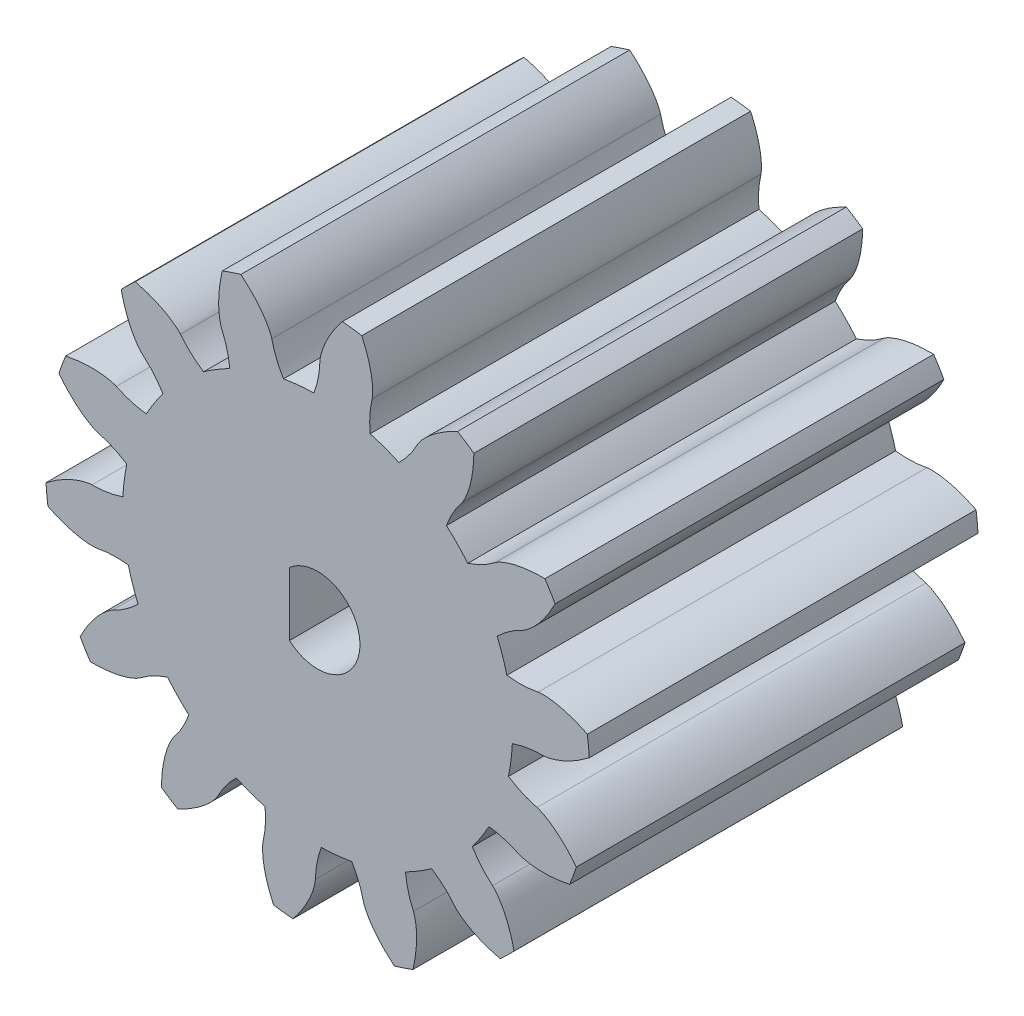
from build123d import *

# Parameters (mm, degrees)
EXTRUDE_1_DEPTH     = 17
CUT_EXTRUDE_1_DEPTH = 14
SKETCH_5_R          = 2.5
CUT_EXTRUDE_2_DEPTH = 10


with BuildPart() as part:
    # 草图3 → 凸台-拉伸1 (new body)
    with BuildSketch(Plane.XY):
        with BuildLine():
            ThreePointArc((-3.841308616, 7.61051727), (-4.427490026, 7.285118878), (-4.986287774, 6.914662626))
            add(Edge.make_bspline(
                [(-4.986287774, 6.914662626), (-5.374015095, 7.164837573), (-5.712687805, 7.469086191), (-5.997843823, 7.832327104)],
                knots=[0, 0, 0, 0, 1, 1, 1, 1], degree=3))
            add(Edge.make_bspline(
                [(-5.997843823, 7.832327104), (-6.02722682, 7.869756111), (-6.060990815, 7.9020808), (-6.129381664, 7.965724859), (-6.164838005, 7.996077789), (-6.273808403, 8.084105708), (-6.350214832, 8.138816882), (-6.585221896, 8.292908353), (-6.749357091, 8.382209705), (-7.257478206, 8.621843869), (-7.612180761, 8.741400879), (-7.975878143, 8.831498618)],
                knots=[0, 0, 0, 0, 0.0625, 0.0625, 0.125, 0.125, 0.25, 0.25, 0.5, 0.5, 1, 1, 1, 1], degree=3))
            ThreePointArc((-7.975878143, 8.831498618), (-8.288227949, 8.539044295), (-8.589861649, 8.235549578))
            add(Edge.make_bspline(
                [(-8.589861649, 8.235549578), (-8.510609476, 7.869170738), (-8.400968963, 7.509224231), (-8.176815523, 6.995154162), (-8.091644293, 6.827136538), (-7.945256312, 6.588944119), (-7.89337007, 6.511759663), (-7.808989012, 6.400674841), (-7.779790112, 6.364414172), (-7.718240864, 6.29414968), (-7.686959773, 6.259380129), (-7.650087487, 6.228614597)],
                knots=[0, 0, 0, 0, 0.5, 0.5, 0.75, 0.75, 0.875, 0.875, 0.9375, 0.9375, 1, 1, 1, 1], degree=3))
            add(Edge.make_bspline(
                [(-7.650087487, 6.228614597), (-7.295506751, 5.932759196), (-7.001487118, 5.585169089), (-6.762979163, 5.190157779)],
                knots=[0, 0, 0, 0, 1, 1, 1, 1], degree=3))
            ThreePointArc((-6.762979163, 5.190157779), (-7.149925292, 4.642649378), (-7.492649722, 4.066426573))
            add(Edge.make_bspline(
                [(-7.492649722, 4.066426573), (-7.950526809, 4.123597832), (-8.387668907, 4.250771784), (-8.802189929, 4.454315979)],
                knots=[0, 0, 0, 0, 1, 1, 1, 1], degree=3))
            add(Edge.make_bspline(
                [(-8.802189929, 4.454315979), (-8.844902932, 4.475289544), (-8.889348398, 4.489763435), (-8.978580545, 4.517431073), (-9.023695248, 4.529394188), (-9.160068066, 4.56142412), (-9.252646169, 4.577565676), (-9.531238001, 4.614431551), (-9.717865106, 4.623673697), (-10.279639779, 4.61911113), (-10.651089581, 4.572928602), (-11.017861544, 4.49630148)],
                knots=[0, 0, 0, 0, 0.0625, 0.0625, 0.125, 0.125, 0.25, 0.25, 0.5, 0.5, 1, 1, 1, 1], degree=3))
            ThreePointArc((-11.017861544, 4.49630148), (-11.172387819, 4.097285738), (-11.31246897, 3.692972489))
            add(Edge.make_bspline(
                [(-11.31246897, 3.692972489), (-11.082099408, 3.39726279), (-10.827141783, 3.120533428), (-10.402139868, 2.754628833), (-10.252503126, 2.640204596), (-10.017264296, 2.489116006), (-9.937027327, 2.442087811), (-9.812804723, 2.378615414), (-9.770764509, 2.358614608), (-9.684823931, 2.322013706), (-9.641554699, 2.30425978), (-9.594985253, 2.292539279)],
                knots=[0, 0, 0, 0, 0.5, 0.5, 0.75, 0.75, 0.875, 0.875, 0.9375, 0.9375, 1, 1, 1, 1], degree=3))
            add(Edge.make_bspline(
                [(-9.594985253, 2.292539279), (-9.147152201, 2.179829589), (-8.73143597, 1.994232061), (-8.345158744, 1.741823892)],
                knots=[0, 0, 0, 0, 1, 1, 1, 1], degree=3))
            ThreePointArc((-8.345158744, 1.741823892), (-8.456230167, 1.080646235), (-8.515000504, 0.412784869))
            add(Edge.make_bspline(
                [(-8.515000504, 0.412784869), (-8.952339185, 0.265628971), (-9.401369315, 0.190539894), (-9.863154368, 0.194072946)],
                knots=[0, 0, 0, 0, 1, 1, 1, 1], degree=3))
            add(Edge.make_bspline(
                [(-9.863154368, 0.194072946), (-9.910737543, 0.194436998), (-9.957061509, 0.188193358), (-10.049461434, 0.174404661), (-10.095298978, 0.165608519), (-10.232063908, 0.135296542), (-10.322477455, 0.109671449), (-10.589475527, 0.022009988), (-10.761630756, -0.050637592), (-11.265792622, -0.298493219), (-11.580419482, -0.501268267), (-11.87762234, -0.729443309)],
                knots=[0, 0, 0, 0, 0.0625, 0.0625, 0.125, 0.125, 0.25, 0.25, 0.5, 0.5, 1, 1, 1, 1], degree=3))
            ThreePointArc((-11.87762234, -0.729443309), (-11.843719261, -1.155990509), (-11.794503073, -1.581043093))
            add(Edge.make_bspline(
                [(-11.794503073, -1.581043093), (-11.45864364, -1.747514719), (-11.108866387, -1.88621729), (-10.567192839, -2.03148452), (-10.382727977, -2.069652246), (-10.105230232, -2.103712058), (-10.012534452, -2.111269482), (-9.873074112, -2.114557967), (-9.826519163, -2.114337506), (-9.733208842, -2.11002556), (-9.686521471, -2.107247479), (-9.639478515, -2.09760156)],
                knots=[0, 0, 0, 0, 0.5, 0.5, 0.75, 0.75, 0.875, 0.875, 0.9375, 0.9375, 1, 1, 1, 1], degree=3))
            add(Edge.make_bspline(
                [(-9.639478515, -2.09760156), (-9.187091976, -2.004842003), (-8.732016845, -1.991687084), (-8.274477289, -2.051499579)],
                knots=[0, 0, 0, 0, 1, 1, 1, 1], degree=3))
            ThreePointArc((-8.274477289, -2.051499579), (-8.087674949, -2.695392149), (-7.850851007, -3.322613941))
            add(Edge.make_bspline(
                [(-7.850851007, -3.322613941), (-8.181030991, -3.644950967), (-8.553013231, -3.907430759), (-8.97060012, -4.104608614)],
                knots=[0, 0, 0, 0, 1, 1, 1, 1], degree=3))
            add(Edge.make_bspline(
                [(-8.97060012, -4.104608614), (-9.013629036, -4.124926181), (-9.052656474, -4.150650721), (-9.129923238, -4.203164733), (-9.167404935, -4.230977948), (-9.277474005, -4.317628175), (-9.347815485, -4.379944554), (-9.550337553, -4.574770923), (-9.673923451, -4.714919485), (-10.020617071, -5.156977325), (-10.216105281, -5.476182809), (-10.384874363, -5.810712905)],
                knots=[0, 0, 0, 0, 0.0625, 0.0625, 0.125, 0.125, 0.25, 0.25, 0.5, 0.5, 1, 1, 1, 1], degree=3))
            ThreePointArc((-10.384874363, -5.810712905), (-10.16925685, -6.180308658), (-9.940491192, -6.5419137))
            add(Edge.make_bspline(
                [(-9.940491192, -6.5419137), (-9.565662967, -6.546175506), (-9.190343761, -6.519379542), (-8.63928367, -6.415237449), (-8.456526216, -6.369589078), (-8.191731388, -6.279874149), (-8.104936333, -6.246463961), (-7.977860088, -6.18891721), (-7.936011183, -6.168519146), (-7.853812372, -6.124148386), (-7.812953868, -6.10138853), (-7.774754837, -6.072286684)],
                knots=[0, 0, 0, 0, 0.5, 0.5, 0.75, 0.75, 0.875, 0.875, 0.9375, 0.9375, 1, 1, 1, 1], degree=3))
            add(Edge.make_bspline(
                [(-7.774754837, -6.072286684), (-7.407415513, -5.792430048), (-7.003114692, -5.583128176), (-6.564934127, -5.438498399)],
                knots=[0, 0, 0, 0, 1, 1, 1, 1], degree=3))
            ThreePointArc((-6.564934127, -5.438498399), (-6.117256519, -5.937575061), (-5.631744183, -6.399928311))
            add(Edge.make_bspline(
                [(-5.631744183, -6.399928311), (-5.789369276, -6.833603662), (-6.01062798, -7.231486828), (-6.301308502, -7.590322098)],
                knots=[0, 0, 0, 0, 1, 1, 1, 1], degree=3))
            add(Edge.make_bspline(
                [(-6.301308502, -7.590322098), (-6.331260753, -7.62729714), (-6.3552618, -7.667407521), (-6.402091773, -7.748245804), (-6.423793913, -7.789567343), (-6.485366595, -7.91539368), (-6.521704015, -8.002058822), (-6.6196381, -8.265462347), (-6.670176964, -8.44535375), (-6.790735414, -8.994058825), (-6.828366136, -9.366472184), (-6.835274656, -9.741099547)],
                knots=[0, 0, 0, 0, 0.0625, 0.0625, 0.125, 0.125, 0.25, 0.25, 0.5, 0.5, 1, 1, 1, 1], degree=3))
            ThreePointArc((-6.835274656, -9.741099547), (-6.480648402, -9.980540881), (-6.117643119, -10.207078067))
            add(Edge.make_bspline(
                [(-6.117643119, -10.207078067), (-5.778085429, -10.04828595), (-5.451560842, -9.86129872), (-5.000258416, -9.528373923), (-4.855405726, -9.407950675), (-4.655759678, -9.212230147), (-4.592056173, -9.144469645), (-4.502533032, -9.037485498), (-4.47367886, -9.000949917), (-4.418872041, -8.925308516), (-4.391934933, -8.887074754), (-4.370145612, -8.844280959)],
                knots=[0, 0, 0, 0, 0.5, 0.5, 0.75, 0.75, 0.875, 0.875, 0.9375, 0.9375, 1, 1, 1, 1], degree=3))
            add(Edge.make_bspline(
                [(-4.370145612, -8.844280959), (-4.160609561, -8.432756282), (-3.887159787, -8.06876226), (-3.555125248, -7.748335911)],
                knots=[0, 0, 0, 0, 1, 1, 1, 1], degree=3))
            ThreePointArc((-3.555125248, -7.748335911), (-2.935240412, -8.003748412), (-2.297201355, -8.209658389))
            add(Edge.make_bspline(
                [(-2.297201355, -8.209658389), (-2.251051974, -8.668777344), (-2.277764142, -9.123258243), (-2.383965454, -9.572679202)],
                knots=[0, 0, 0, 0, 1, 1, 1, 1], degree=3))
            add(Edge.make_bspline(
                [(-2.383965454, -9.572679202), (-2.394908631, -9.618988358), (-2.399129584, -9.665540227), (-2.406247516, -9.758691767), (-2.407871725, -9.805337393), (-2.408752793, -9.94541839), (-2.403889081, -10.039267201), (-2.377838136, -10.319077583), (-2.345320125, -10.503082128), (-2.215865325, -11.04975667), (-2.088185334, -11.401616871), (-1.931864974, -11.742141956)],
                knots=[0, 0, 0, 0, 0.0625, 0.0625, 0.125, 0.125, 0.25, 0.25, 0.5, 0.5, 1, 1, 1, 1], degree=3))
            ThreePointArc((-1.931864974, -11.742141956), (-1.508468058, -11.80400458), (-1.083120798, -11.850605442))
            add(Edge.make_bspline(
                [(-1.083120798, -11.850605442), (-0.846087208, -11.560210127), (-0.633029439, -11.250066746), (-0.370870658, -10.754299085), (-0.292612584, -10.58295226), (-0.197657664, -10.319990984), (-0.16966297, -10.231300966), (-0.135424088, -10.096068945), (-0.125279572, -10.050632168), (-0.108719908, -9.958701833), (-0.10103942, -9.912566831), (-0.099975453, -9.864556922)],
                knots=[0, 0, 0, 0, 0.5, 0.5, 0.75, 0.75, 0.875, 0.875, 0.9375, 0.9375, 1, 1, 1, 1], degree=3))
            add(Edge.make_bspline(
                [(-0.099975453, -9.864556922), (-0.089743859, -9.402871714), (-0.001305213, -8.956279022), (0.158819788, -8.52352047)],
                knots=[0, 0, 0, 0, 1, 1, 1, 1], degree=3))
            ThreePointArc((0.158819788, -8.52352047), (0.828136057, -8.484681231), (1.492330374, -8.393364938))
            add(Edge.make_bspline(
                [(1.492330374, -8.393364938), (1.733113779, -8.786993357), (1.906238819, -9.208056474), (2.005551189, -9.659049789)],
                knots=[0, 0, 0, 0, 1, 1, 1, 1], degree=3))
            add(Edge.make_bspline(
                [(2.005551189, -9.659049789), (2.015784518, -9.705520963), (2.032179669, -9.74929415), (2.066183572, -9.836309143), (2.084958989, -9.879040118), (2.144944042, -10.005631016), (2.190045568, -10.088075587), (2.334921833, -10.32887295), (2.444056128, -10.48054628), (2.797884067, -10.91691469), (3.065586184, -11.178531505), (3.354174259, -11.417509143)],
                knots=[0, 0, 0, 0, 0.0625, 0.0625, 0.125, 0.125, 0.25, 0.25, 0.5, 0.5, 1, 1, 1, 1], degree=3))
            ThreePointArc((3.354174259, -11.417509143), (3.762482885, -11.289540404), (4.165926881, -11.146975071))
            add(Edge.make_bspline(
                [(4.165926881, -11.146975071), (4.253488961, -10.782492913), (4.310881208, -10.41062108), (4.331972581, -9.850203419), (4.328136069, -9.661870359), (4.299592874, -9.38375104), (4.286334065, -9.291697652), (4.258507257, -9.155002117), (4.247932872, -9.109663455), (4.222965536, -9.019652117), (4.209868189, -8.974753477), (4.189996071, -8.931036405)],
                knots=[0, 0, 0, 0, 0.5, 0.5, 0.75, 0.75, 0.875, 0.875, 0.9375, 0.9375, 1, 1, 1, 1], degree=3))
            add(Edge.make_bspline(
                [(4.189996071, -8.931036405), (3.998896715, -8.510633084), (3.884807874, -8.069894881), (3.841308616, -7.610517265)],
                knots=[0, 0, 0, 0, 1, 1, 1, 1], degree=3))
            ThreePointArc((3.841308616, -7.610517265), (4.427490024, -7.285118874), (4.986287771, -6.914662623))
            add(Edge.make_bspline(
                [(4.986287771, -6.914662623), (5.374015093, -7.16483757), (5.712687804, -7.46908619), (5.997843823, -7.832327104)],
                knots=[0, 0, 0, 0, 1, 1, 1, 1], degree=3))
            add(Edge.make_bspline(
                [(5.997843823, -7.832327104), (6.02722682, -7.869756111), (6.060990815, -7.9020808), (6.129381664, -7.965724859), (6.164838005, -7.996077789), (6.273808403, -8.084105708), (6.350214832, -8.138816882), (6.585221896, -8.292908353), (6.749357091, -8.382209705), (7.257478206, -8.621843869), (7.612180761, -8.741400879), (7.975878143, -8.831498618)],
                knots=[0, 0, 0, 0, 0.0625, 0.0625, 0.125, 0.125, 0.25, 0.25, 0.5, 0.5, 1, 1, 1, 1], degree=3))
            ThreePointArc((7.975878143, -8.831498618), (8.288227949, -8.539044295), (8.589861649, -8.235549578))
            add(Edge.make_bspline(
                [(8.589861649, -8.235549578), (8.510609476, -7.869170738), (8.400968963, -7.509224231), (8.176815523, -6.995154162), (8.091644293, -6.827136538), (7.945256312, -6.588944119), (7.893370071, -6.511759663), (7.808989012, -6.400674841), (7.779790113, -6.364414172), (7.718240864, -6.29414968), (7.686959773, -6.259380129), (7.650087487, -6.228614597)],
                knots=[0, 0, 0, 0, 0.5, 0.5, 0.75, 0.75, 0.875, 0.875, 0.9375, 0.9375, 1, 1, 1, 1], degree=3))
            add(Edge.make_bspline(
                [(7.650087487, -6.228614597), (7.295506751, -5.932759196), (7.001487118, -5.585169089), (6.762979163, -5.190157779)],
                knots=[0, 0, 0, 0, 1, 1, 1, 1], degree=3))
            ThreePointArc((6.762979163, -5.190157779), (7.149925292, -4.642649378), (7.492649722, -4.066426573))
            add(Edge.make_bspline(
                [(7.492649722, -4.066426573), (7.950526809, -4.123597832), (8.387668907, -4.250771784), (8.802189929, -4.454315979)],
                knots=[0, 0, 0, 0, 1, 1, 1, 1], degree=3))
            add(Edge.make_bspline(
                [(8.802189929, -4.454315979), (8.844902932, -4.475289545), (8.889348398, -4.489763435), (8.978580545, -4.517431073), (9.023695248, -4.529394188), (9.160068066, -4.56142412), (9.252646169, -4.577565676), (9.531238001, -4.614431551), (9.717865106, -4.623673697), (10.279639779, -4.61911113), (10.651089581, -4.572928602), (11.017861544, -4.49630148)],
                knots=[0, 0, 0, 0, 0.0625, 0.0625, 0.125, 0.125, 0.25, 0.25, 0.5, 0.5, 1, 1, 1, 1], degree=3))
            ThreePointArc((11.017861544, -4.49630148), (11.172387819, -4.097285738), (11.31246897, -3.692972489))
            add(Edge.make_bspline(
                [(11.31246897, -3.692972489), (11.082099408, -3.39726279), (10.827141783, -3.120533428), (10.402139868, -2.754628833), (10.252503126, -2.640204596), (10.017264296, -2.489116006), (9.937027327, -2.442087811), (9.812804723, -2.378615414), (9.770764509, -2.358614608), (9.684823931, -2.322013706), (9.641554699, -2.30425978), (9.594985253, -2.292539279)],
                knots=[0, 0, 0, 0, 0.5, 0.5, 0.75, 0.75, 0.875, 0.875, 0.9375, 0.9375, 1, 1, 1, 1], degree=3))
            add(Edge.make_bspline(
                [(9.594985253, -2.292539279), (9.147152201, -2.179829589), (8.73143597, -1.994232061), (8.345158744, -1.741823892)],
                knots=[0, 0, 0, 0, 1, 1, 1, 1], degree=3))
            ThreePointArc((8.345158744, -1.741823892), (8.456230167, -1.080646234), (8.515000504, -0.412784869))
            add(Edge.make_bspline(
                [(8.515000504, -0.412784869), (8.952339185, -0.26562897), (9.401369315, -0.190539894), (9.863154368, -0.194072946)],
                knots=[0, 0, 0, 0, 1, 1, 1, 1], degree=3))
            add(Edge.make_bspline(
                [(9.863154368, -0.194072946), (9.910737543, -0.194436998), (9.957061509, -0.188193358), (10.049461434, -0.174404661), (10.095298978, -0.165608519), (10.232063908, -0.135296542), (10.322477455, -0.109671449), (10.589475527, -0.022009988), (10.761630756, 0.050637592), (11.265792622, 0.298493219), (11.580419482, 0.501268267), (11.87762234, 0.729443309)],
                knots=[0, 0, 0, 0, 0.0625, 0.0625, 0.125, 0.125, 0.25, 0.25, 0.5, 0.5, 1, 1, 1, 1], degree=3))
            ThreePointArc((11.87762234, 0.729443309), (11.843719261, 1.155990509), (11.794503073, 1.581043093))
            add(Edge.make_bspline(
                [(11.794503073, 1.581043093), (11.45864364, 1.747514719), (11.108866387, 1.88621729), (10.567192839, 2.03148452), (10.382727977, 2.069652246), (10.105230232, 2.103712058), (10.012534452, 2.111269482), (9.873074112, 2.114557967), (9.826519163, 2.114337506), (9.733208842, 2.11002556), (9.686521471, 2.107247479), (9.639478515, 2.09760156)],
                knots=[0, 0, 0, 0, 0.5, 0.5, 0.75, 0.75, 0.875, 0.875, 0.9375, 0.9375, 1, 1, 1, 1], degree=3))
            add(Edge.make_bspline(
                [(9.639478515, 2.09760156), (9.187091976, 2.004842003), (8.732016845, 1.991687084), (8.274477289, 2.051499579)],
                knots=[0, 0, 0, 0, 1, 1, 1, 1], degree=3))
            ThreePointArc((8.274477289, 2.051499579), (8.087674949, 2.695392149), (7.850851007, 3.322613941))
            add(Edge.make_bspline(
                [(7.850851007, 3.322613941), (8.181030991, 3.644950967), (8.553013231, 3.907430759), (8.97060012, 4.104608614)],
                knots=[0, 0, 0, 0, 1, 1, 1, 1], degree=3))
            add(Edge.make_bspline(
                [(8.97060012, 4.104608614), (9.013629036, 4.12492618), (9.052656473, 4.150650721), (9.129923238, 4.203164733), (9.167404935, 4.230977948), (9.277474005, 4.317628175), (9.347815485, 4.379944554), (9.550337553, 4.574770923), (9.673923451, 4.714919485), (10.020617071, 5.156977325), (10.216105281, 5.476182809), (10.384874363, 5.810712905)],
                knots=[0, 0, 0, 0, 0.0625, 0.0625, 0.125, 0.125, 0.25, 0.25, 0.5, 0.5, 1, 1, 1, 1], degree=3))
            ThreePointArc((10.384874363, 5.810712905), (10.16925685, 6.180308658), (9.940491192, 6.5419137))
            add(Edge.make_bspline(
                [(9.940491192, 6.5419137), (9.565662967, 6.546175506), (9.190343761, 6.519379542), (8.63928367, 6.415237449), (8.456526216, 6.369589078), (8.191731388, 6.279874149), (8.104936333, 6.246463961), (7.977860088, 6.18891721), (7.936011183, 6.168519146), (7.853812372, 6.124148386), (7.812953868, 6.10138853), (7.774754837, 6.072286684)],
                knots=[0, 0, 0, 0, 0.5, 0.5, 0.75, 0.75, 0.875, 0.875, 0.9375, 0.9375, 1, 1, 1, 1], degree=3))
            add(Edge.make_bspline(
                [(7.774754837, 6.072286684), (7.407415513, 5.792430047), (7.003114692, 5.583128176), (6.564934127, 5.438498399)],
                knots=[0, 0, 0, 0, 1, 1, 1, 1], degree=3))
            ThreePointArc((6.564934127, 5.438498399), (6.117256519, 5.937575061), (5.631744183, 6.399928311))
            add(Edge.make_bspline(
                [(5.631744183, 6.399928311), (5.789369276, 6.833603662), (6.01062798, 7.231486828), (6.301308502, 7.590322098)],
                knots=[0, 0, 0, 0, 1, 1, 1, 1], degree=3))
            add(Edge.make_bspline(
                [(6.301308502, 7.590322098), (6.331260753, 7.62729714), (6.3552618, 7.667407521), (6.402091773, 7.748245804), (6.423793913, 7.789567343), (6.485366595, 7.91539368), (6.521704015, 8.002058822), (6.6196381, 8.265462346), (6.670176964, 8.44535375), (6.790735414, 8.994058825), (6.828366136, 9.366472184), (6.835274656, 9.741099547)],
                knots=[0, 0, 0, 0, 0.0625, 0.0625, 0.125, 0.125, 0.25, 0.25, 0.5, 0.5, 1, 1, 1, 1], degree=3))
            ThreePointArc((6.835274656, 9.741099547), (6.480648402, 9.980540881), (6.117643119, 10.207078067))
            add(Edge.make_bspline(
                [(6.117643119, 10.207078067), (5.778085429, 10.04828595), (5.451560842, 9.86129872), (5.000258416, 9.528373923), (4.855405726, 9.407950675), (4.655759678, 9.212230147), (4.592056173, 9.144469645), (4.502533031, 9.037485498), (4.47367886, 9.000949917), (4.418872041, 8.925308516), (4.391934933, 8.887074754), (4.370145612, 8.844280959)],
                knots=[0, 0, 0, 0, 0.5, 0.5, 0.75, 0.75, 0.875, 0.875, 0.9375, 0.9375, 1, 1, 1, 1], degree=3))
            add(Edge.make_bspline(
                [(4.370145612, 8.844280959), (4.160609561, 8.432756282), (3.887159787, 8.06876226), (3.555125248, 7.748335911)],
                knots=[0, 0, 0, 0, 1, 1, 1, 1], degree=3))
            ThreePointArc((3.555125248, 7.748335911), (2.935240412, 8.003748412), (2.297201355, 8.209658389))
            add(Edge.make_bspline(
                [(2.297201355, 8.209658389), (2.251051974, 8.668777344), (2.277764142, 9.123258243), (2.383965454, 9.572679202)],
                knots=[0, 0, 0, 0, 1, 1, 1, 1], degree=3))
            add(Edge.make_bspline(
                [(2.383965454, 9.572679202), (2.394908631, 9.618988358), (2.399129584, 9.665540227), (2.406247516, 9.758691767), (2.407871725, 9.805337393), (2.408752792, 9.94541839), (2.403889081, 10.039267201), (2.377838136, 10.319077583), (2.345320125, 10.503082128), (2.215865325, 11.04975667), (2.088185334, 11.401616871), (1.931864974, 11.742141956)],
                knots=[0, 0, 0, 0, 0.0625, 0.0625, 0.125, 0.125, 0.25, 0.25, 0.5, 0.5, 1, 1, 1, 1], degree=3))
            ThreePointArc((1.931864974, 11.742141956), (1.508468058, 11.80400458), (1.083120798, 11.850605442))
            add(Edge.make_bspline(
                [(1.083120798, 11.850605442), (0.846087208, 11.560210127), (0.633029439, 11.250066746), (0.370870658, 10.754299085), (0.292612584, 10.58295226), (0.197657664, 10.319990984), (0.16966297, 10.231300966), (0.135424088, 10.096068945), (0.125279572, 10.050632168), (0.108719908, 9.958701833), (0.10103942, 9.912566831), (0.099975453, 9.864556922)],
                knots=[0, 0, 0, 0, 0.5, 0.5, 0.75, 0.75, 0.875, 0.875, 0.9375, 0.9375, 1, 1, 1, 1], degree=3))
            add(Edge.make_bspline(
                [(0.099975453, 9.864556922), (0.089743859, 9.402871714), (0.001305213, 8.956279021), (-0.158819787, 8.52352047)],
                knots=[0, 0, 0, 0, 1, 1, 1, 1], degree=3))
            ThreePointArc((-0.158819787, 8.52352047), (-0.828136057, 8.484681231), (-1.492330374, 8.393364938))
            add(Edge.make_bspline(
                [(-1.492330374, 8.393364938), (-1.733113779, 8.786993357), (-1.906238819, 9.208056474), (-2.005551189, 9.659049789)],
                knots=[0, 0, 0, 0, 1, 1, 1, 1], degree=3))
            add(Edge.make_bspline(
                [(-2.005551189, 9.659049789), (-2.015784518, 9.705520963), (-2.032179669, 9.74929415), (-2.066183572, 9.836309143), (-2.084958989, 9.879040118), (-2.144944042, 10.005631016), (-2.190045568, 10.088075587), (-2.334921833, 10.32887295), (-2.444056129, 10.48054628), (-2.797884067, 10.91691469), (-3.065586184, 11.178531505), (-3.354174259, 11.417509143)],
                knots=[0, 0, 0, 0, 0.0625, 0.0625, 0.125, 0.125, 0.25, 0.25, 0.5, 0.5, 1, 1, 1, 1], degree=3))
            ThreePointArc((-3.354174259, 11.417509143), (-3.762482885, 11.289540404), (-4.165926881, 11.146975071))
            add(Edge.make_bspline(
                [(-4.165926881, 11.146975071), (-4.253488961, 10.782492913), (-4.310881208, 10.41062108), (-4.331972581, 9.850203419), (-4.328136069, 9.661870359), (-4.299592874, 9.38375104), (-4.286334065, 9.291697652), (-4.258507257, 9.155002117), (-4.247932872, 9.109663455), (-4.222965536, 9.019652117), (-4.209868189, 8.974753477), (-4.189996071, 8.931036405)],
                knots=[0, 0, 0, 0, 0.5, 0.5, 0.75, 0.75, 0.875, 0.875, 0.9375, 0.9375, 1, 1, 1, 1], degree=3))
            add(Edge.make_bspline(
                [(-4.189996071, 8.931036405), (-3.998896715, 8.510633086), (-3.884807875, 8.069894884), (-3.841308616, 7.61051727)],
                knots=[0, 0, 0, 0, 1, 1, 1, 1], degree=3))
        make_face()
    extrude(amount=EXTRUDE_1_DEPTH)

    # 草图4 → 切除-拉伸1 (cut)
    with BuildSketch(Plane.XY.offset(17)):
        with BuildLine():
            Line((-1.23025, 1.381660211), (-1.23025, -1.381660211))
            ThreePointArc((-1.23025, -1.381660211), (0.757145131, -1.687966602), (1.85, 0))
            ThreePointArc((1.85, 0), (0.757145131, 1.687966602), (-1.23025, 1.381660211))
        make_face()
    extrude(amount=-CUT_EXTRUDE_1_DEPTH, mode=Mode.SUBTRACT)

    # 草图5 → 切除-拉伸2 (cut)
    with BuildSketch(Plane(origin=(0, 0, 0), x_dir=(-1, 0, 0), z_dir=(0, 0, -1))):
        Circle(SKETCH_5_R)
    extrude(amount=-CUT_EXTRUDE_2_DEPTH, mode=Mode.SUBTRACT)


solid = part.part
